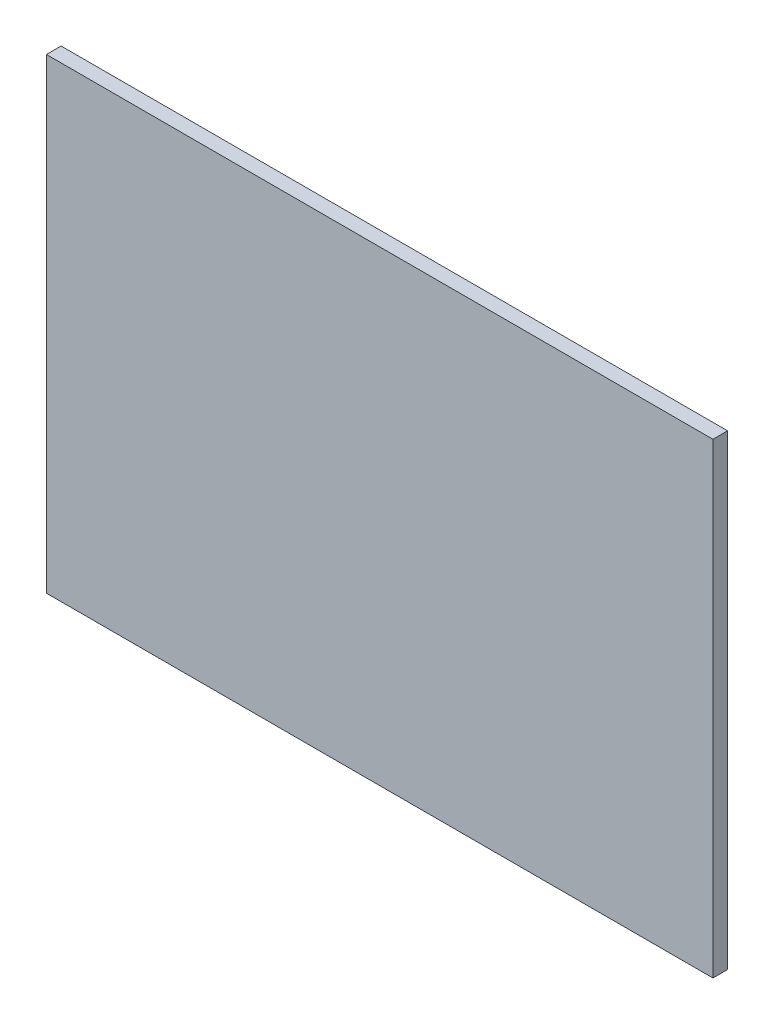
from build123d import *

# Parameters (mm, degrees)
SKETCH_1_W      = 50
SKETCH_1_H      = 35
EXTRUDE_1_DEPTH = 1.1


with BuildPart() as part:
    # 草图1 → 凸台-拉伸1 (new body)
    with BuildSketch(Plane.XY):
        Rectangle(SKETCH_1_W, SKETCH_1_H)
    extrude(amount=EXTRUDE_1_DEPTH)


solid = part.part
